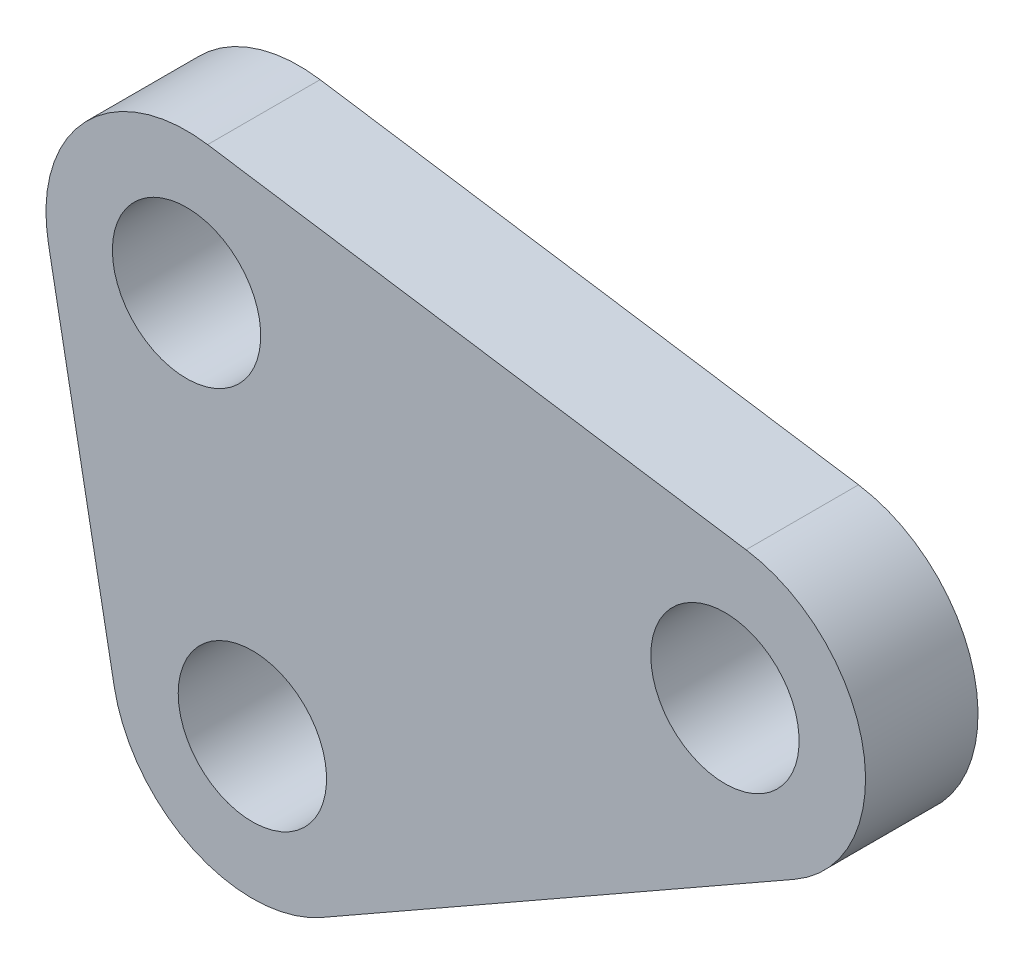
from build123d import *

# Parameters (mm, degrees)
SKETCH1_R           = 2.6375
BOSS_EXTRUDE1_DEPTH = 4


with BuildPart() as part:
    # Sketch1 → Boss-Extrude1 (new body)
    with BuildSketch(Plane.XY.offset(4)):
        with BuildLine():
            Line((46.037988185, 74.138222759), (26.891590001, 77.042584155))
            ThreePointArc((26.891590001, 77.042584155), (22.54509271, 75.572516008), (21.227396241, 71.177426126))
            Line((21.227396241, 71.177426126), (23.568249259, 58.696629092))
            ThreePointArc((23.568249259, 58.696629092), (26.381296021, 55.081304051), (30.958043521, 55.274150009))
            Line((30.958043521, 55.274150009), (47.763588686, 64.850585648))
            ThreePointArc((47.763588686, 64.850585648), (50.20397723, 70.108121575), (46.037988185, 74.138222759))
        make_face()
        with Locations((45.288105172, 69.194775028)):
            Circle(SKETCH1_R, mode=Mode.SUBTRACT)
        with Locations((26.141706988, 72.099136424)):
            Circle(SKETCH1_R, mode=Mode.SUBTRACT)
        with Locations((28.482560007, 59.618339389)):
            Circle(SKETCH1_R, mode=Mode.SUBTRACT)
    extrude(amount=-BOSS_EXTRUDE1_DEPTH)


solid = part.part
